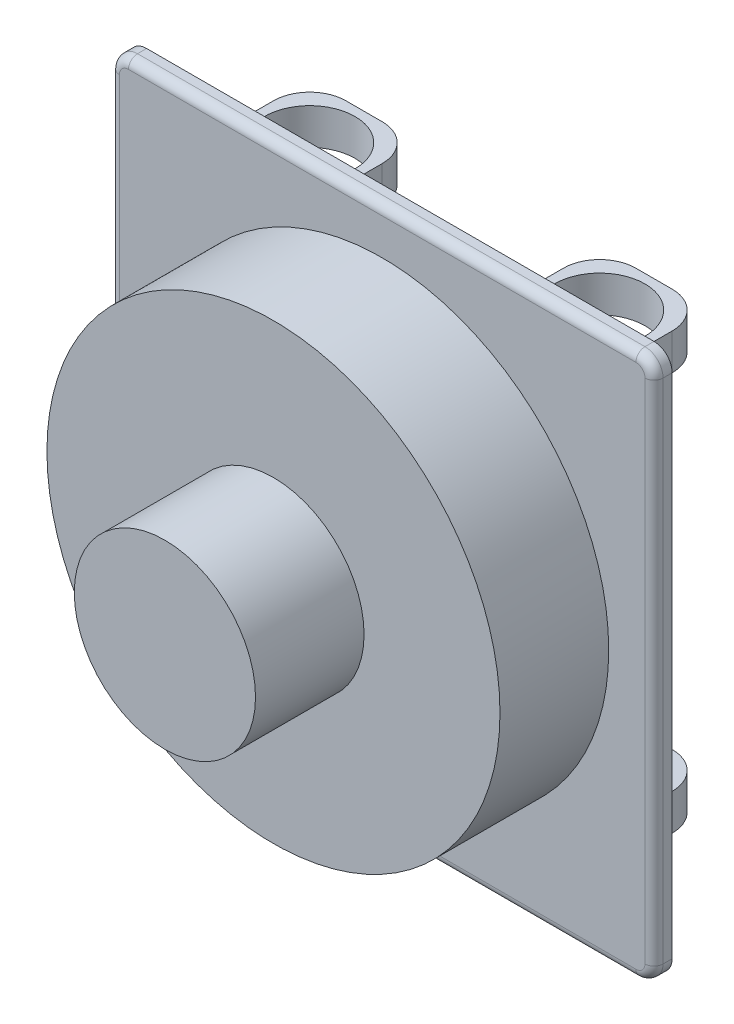
from build123d import *

# Parameters (mm, degrees)
BOSS_EXTRUDE1_DEPTH = 10
FILLET1_R           = 5
SKETCH3_W           = 60
SKETCH3_H           = 20
BOSS_EXTRUDE2_DEPTH = 60
FILLET2_R           = 20
SKETCH6_R           = 25
CUT_EXTRUDE1_DEPTH  = 271.0000001
SKETCH7_R           = 125
BOSS_EXTRUDE3_DEPTH = 60
SKETCH8_R           = 50
BOSS_EXTRUDE5_DEPTH = 59.9


with BuildPart() as part:
    # Sketch2 → Boss-Extrude1 (new body)
    with BuildSketch(Plane.XY):
        with BuildLine():
            Line((-140, 150), (140, 150))
            ThreePointArc((140, 150), (147.071067812, 147.071067812), (150, 140))
            Line((150, 140), (150, -140))
            ThreePointArc((150, -140), (147.071067812, -147.071067812), (140, -150))
            Line((140, -150), (-140, -150))
            ThreePointArc((-140, -150), (-147.071067812, -147.071067812), (-150, -140))
            Line((-150, -140), (-150, 140))
            ThreePointArc((-150, 140), (-147.071067812, 147.071067812), (-140, 150))
        make_face()
    extrude(amount=BOSS_EXTRUDE1_DEPTH)

    # Fillet1
    fillet1_edges = [part.edges().sort_by_distance(p)[0] for p in [
        (147.071067812, -147.071067812, 10),
        (150, 0, 10),
        (147.071067812, 147.071067812, 10),
        (0, 150, 10),
        (-147.071067812, 147.071067812, 10),
        (-150, 0, 10),
        (-147.071067812, -147.071067812, 10),
        (0, -150, 10),
    ]]
    fillet(fillet1_edges, radius=FILLET1_R)

    # Sketch3 → Boss-Extrude2 (add)
    with BuildSketch(Plane(origin=(0, 0, 0), x_dir=(-1, 0, 0), z_dir=(0, 0, -1))):
        with Locations((80, 110)):
            Rectangle(SKETCH3_W, SKETCH3_H)
        with Locations((-80, 110)):
            Rectangle(SKETCH3_W, SKETCH3_H)
        with Locations((80, -110)):
            Rectangle(SKETCH3_W, SKETCH3_H)
        with Locations((-80, -110)):
            Rectangle(SKETCH3_W, SKETCH3_H)
    extrude(amount=BOSS_EXTRUDE2_DEPTH)

    # Fillet2
    fillet2_edges = [part.edges().sort_by_distance(p)[0] for p in [
        (-110, 110, -60),
        (-50, 110, -60),
        (50, 110, -60),
        (110, 110, -60),
        (-50, -110, -60),
        (-110, -110, -60),
        (110, -110, -60),
        (50, -110, -60),
    ]]
    fillet(fillet2_edges, radius=FILLET2_R)

    # Sketch6 → Cut-Extrude1 (cut, through all)
    with BuildSketch(Plane.XZ.offset(120)):
        with Locations((-80, -30)):
            Circle(SKETCH6_R)
        with Locations((80, -30)):
            Circle(SKETCH6_R)
    extrude(amount=-CUT_EXTRUDE1_DEPTH, mode=Mode.SUBTRACT)

    # Sketch7 → Boss-Extrude3 (add)
    with BuildSketch(Plane.XY.offset(10)):
        Circle(SKETCH7_R)
    extrude(amount=BOSS_EXTRUDE3_DEPTH)

    # Sketch8 → Boss-Extrude5 (add)
    with BuildSketch(Plane.XY.offset(70)):
        Circle(SKETCH8_R)
    extrude(amount=BOSS_EXTRUDE5_DEPTH)


solid = part.part
